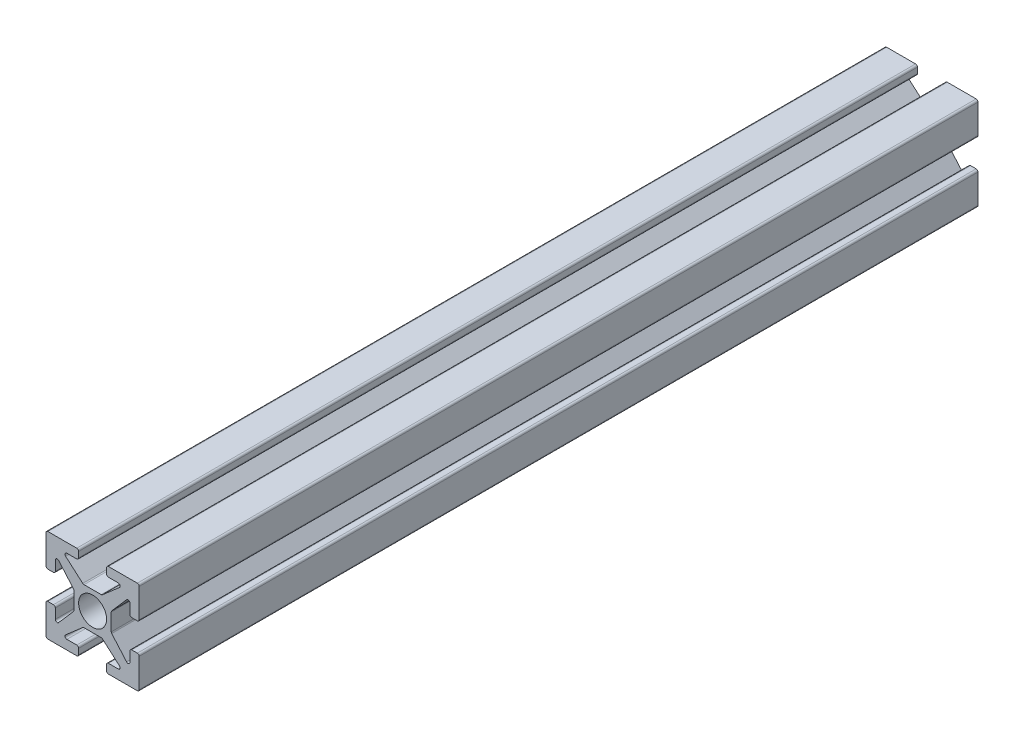
from build123d import *

# Parameters (mm, degrees)
SKETCH1_W           = 10
SKETCH1_H           = 90
BOSS_EXTRUDE1_DEPTH = 10
CUT_EXTRUDE1_DEPTH  = 91
CUT_EXTRUDE2_DEPTH  = 91
CUT_EXTRUDE3_DEPTH  = 91
CUT_EXTRUDE4_DEPTH  = 91
FILLET1_R           = 0.2


with BuildPart() as part:
    # Sketch1 → Boss-Extrude1 (new body)
    with BuildSketch(Plane(origin=(0, 5, 0), x_dir=(1, 0, 0), z_dir=(0, 1, 0))):
        Rectangle(SKETCH1_W, SKETCH1_H)
    extrude(amount=-BOSS_EXTRUDE1_DEPTH)

    # Sketch2 → Cut-Extrude1 (cut, through all)
    with BuildSketch(Plane.XY.offset(45)):
        with BuildLine():
            Line((5, 1.5), (4, 1.5))
            Line((4, 1.5), (4, 2.759344808))
            ThreePointArc((4, 2.759344808), (3.870199868, 2.946619949), (3.649280215, 2.890811711))
            Line((3.649280215, 2.890811711), (2, 1))
            Line((2, 1), (2, -1))
            Line((2, -1), (3.649280215, -2.890811711))
            ThreePointArc((3.649280215, -2.890811711), (3.870199868, -2.946619949), (4, -2.759344808))
            Line((4, -2.759344808), (4, -1.5))
            Line((4, -1.5), (5, -1.5))
            Line((5, -1.5), (5, 1.5))
        make_face()
    extrude(amount=-CUT_EXTRUDE1_DEPTH, mode=Mode.SUBTRACT)

    # Sketch3 → Cut-Extrude2 (cut, through all)
    with BuildSketch(Plane.XY.offset(45)):
        with BuildLine():
            Line((1.5, -5), (1.5, -4))
            Line((1.5, -4), (2.759344808, -4))
            ThreePointArc((2.759344808, -4), (2.946619949, -3.870199868), (2.890811711, -3.649280215))
            Line((2.890811711, -3.649280215), (1, -2))
            Line((1, -2), (-1, -2))
            Line((-1, -2), (-2.890811711, -3.649280215))
            ThreePointArc((-2.890811711, -3.649280215), (-2.946619949, -3.870199868), (-2.759344808, -4))
            Line((-2.759344808, -4), (-1.5, -4))
            Line((-1.5, -4), (-1.5, -5))
            Line((-1.5, -5), (1.5, -5))
        make_face()
    extrude(amount=-CUT_EXTRUDE2_DEPTH, mode=Mode.SUBTRACT)

    # Sketch4 → Cut-Extrude3 (cut, through all)
    with BuildSketch(Plane.XY.offset(45)):
        with BuildLine():
            Line((-5, -1.5), (-4, -1.5))
            Line((-4, -1.5), (-4, -2.759344808))
            ThreePointArc((-4, -2.759344808), (-3.870199868, -2.946619949), (-3.649280215, -2.890811711))
            Line((-3.649280215, -2.890811711), (-2, -1))
            Line((-2, -1), (-2, 1))
            Line((-2, 1), (-3.649280215, 2.890811711))
            ThreePointArc((-3.649280215, 2.890811711), (-3.870199868, 2.946619949), (-4, 2.759344808))
            Line((-4, 2.759344808), (-4, 1.5))
            Line((-4, 1.5), (-5, 1.5))
            Line((-5, 1.5), (-5, -1.5))
        make_face()
    extrude(amount=-CUT_EXTRUDE3_DEPTH, mode=Mode.SUBTRACT)

    # Sketch5 → Cut-Extrude4 (cut, through all)
    with BuildSketch(Plane.XY.offset(45)):
        with BuildLine():
            Line((-1.5, 5), (-1.5, 4))
            Line((-1.5, 4), (-2.759344808, 4))
            ThreePointArc((-2.759344808, 4), (-2.946619949, 3.870199868), (-2.890811711, 3.649280215))
            Line((-2.890811711, 3.649280215), (-1, 2))
            Line((-1, 2), (1, 2))
            Line((1, 2), (2.890811711, 3.649280215))
            ThreePointArc((2.890811711, 3.649280215), (2.946619949, 3.870199868), (2.759344808, 4))
            Line((2.759344808, 4), (1.5, 4))
            Line((1.5, 4), (1.5, 5))
            Line((1.5, 5), (-1.5, 5))
        make_face()
    extrude(amount=-CUT_EXTRUDE4_DEPTH, mode=Mode.SUBTRACT)

    # Sketch6 → Cut-Revolve1 (revolve, cut)
    with BuildSketch(Plane(origin=(0, 0, 0), x_dir=(1, 0, 0), z_dir=(0, 1, 0))):
        Polygon((1.499999999, 37), (1.25, 36.849784845), (1.25, -36.849784845), (1.499999999, -37), (1.499999999, -45), (0, -45), (0, 45), (1.499999999, 45), align=None)
    revolve(axis=Axis((0, 0, -45), (0, 0, 1)), mode=Mode.SUBTRACT)

    # Fillet1
    fillet1_edges = [part.edges().sort_by_distance(p)[0] for p in [
        (-5, -5, 0),
        (-1.5, 5, 0),
        (1.5, 5, 0),
        (1.5, 4, 0),
        (1, 2, 0),
        (-1, 2, 0),
        (-1.5, 4, 0),
        (5, 1.5, 0),
        (5, -1.5, 0),
        (4, -1.5, 0),
        (2, -1, 0),
        (2, 1, 0),
        (4, 1.5, 0),
        (5, -5, 0),
        (-5, 5, 0),
        (5, 5, 0),
        (1.5, -5, 0),
        (-1.5, -5, 0),
        (-1.5, -4, 0),
        (-1, -2, 0),
        (1, -2, 0),
        (1.5, -4, 0),
        (-5, -1.5, 0),
        (-5, 1.5, 0),
        (-4, 1.5, 0),
        (-2, 1, 0),
        (-2, -1, 0),
        (-4, -1.5, 0),
    ]]
    fillet(fillet1_edges, radius=FILLET1_R)


solid = part.part
